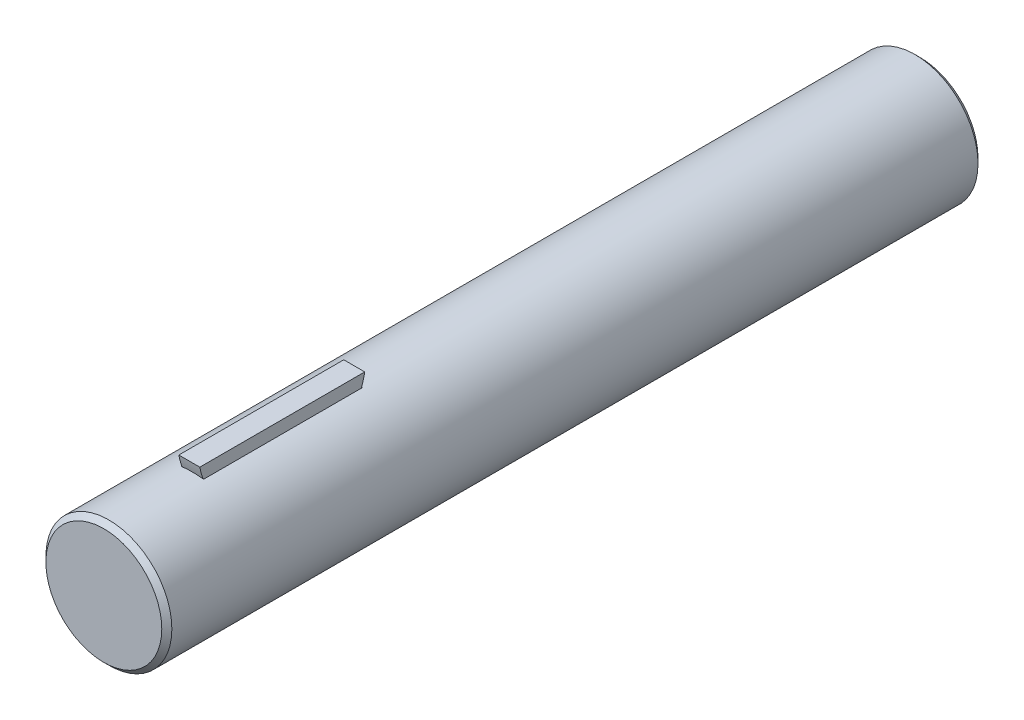
from build123d import *

# Parameters (mm, degrees)
CUT_EXTRUDE1_DEPTH       = 0.84455
CUT_EXTRUDE1_DEPTH_BACK  = 0.84455
BOSS_EXTRUDE1_DEPTH      = 0.79375
BOSS_EXTRUDE1_DEPTH_BACK = 0.79375


with BuildPart() as part:
    # Sketch1 → Revolve1 (revolve)
    with BuildSketch(Plane(origin=(0, 0, 0), x_dir=(0, 0, -1), z_dir=(1, 0, 0))):
        Polygon((-44.323, 0), (-44.323, 4.3815), (-43.942, 4.7625), (17.018, 4.7625), (17.399, 4.3815), (17.399, 0), align=None)
    revolve(axis=Axis((0, 0, -17.399), (0, 0, 1)))

    # Sketch2 → Cut-Extrude1 (cut, two sides: drawn at the far end of the back side and taken through both)
    with BuildSketch(Plane(origin=(0, 0, 0), x_dir=(0, 0, -1), z_dir=(1, 0, 0)).offset(-CUT_EXTRUDE1_DEPTH_BACK)):
        with BuildLine():
            Line((-25.3873, 5.5753), (-37.8587, 5.5753))
            ThreePointArc((-37.8587, 5.5753), (-31.623, 0.424693809), (-25.3873, 5.5753))
        make_face()
    extrude(amount=CUT_EXTRUDE1_DEPTH + CUT_EXTRUDE1_DEPTH_BACK, mode=Mode.SUBTRACT)

    # Sketch3 → Boss-Extrude1 (add, two sides: drawn at the far end of the back side and taken through both)
    with BuildSketch(Plane(origin=(0, 0, 0), x_dir=(0, 0, -1), z_dir=(1, 0, 0)).offset(-BOSS_EXTRUDE1_DEPTH_BACK)):
        with BuildLine():
            Line((-31.75, 0.425963936), (-31.75, 0.169400396))
            Line((-31.75, 0.169400396), (-31.496, 0.169400396))
            Line((-31.496, 0.169400396), (-31.496, 0.425963936))
            ThreePointArc((-31.496, 0.425963936), (-27.530335428, 1.919531948), (-25.3873, 5.5753))
            Line((-25.3873, 5.5753), (-37.8587, 5.5753))
            ThreePointArc((-37.8587, 5.5753), (-35.715664572, 1.919531948), (-31.75, 0.425963936))
        make_face()
    extrude(amount=BOSS_EXTRUDE1_DEPTH + BOSS_EXTRUDE1_DEPTH_BACK)


solid = part.part
